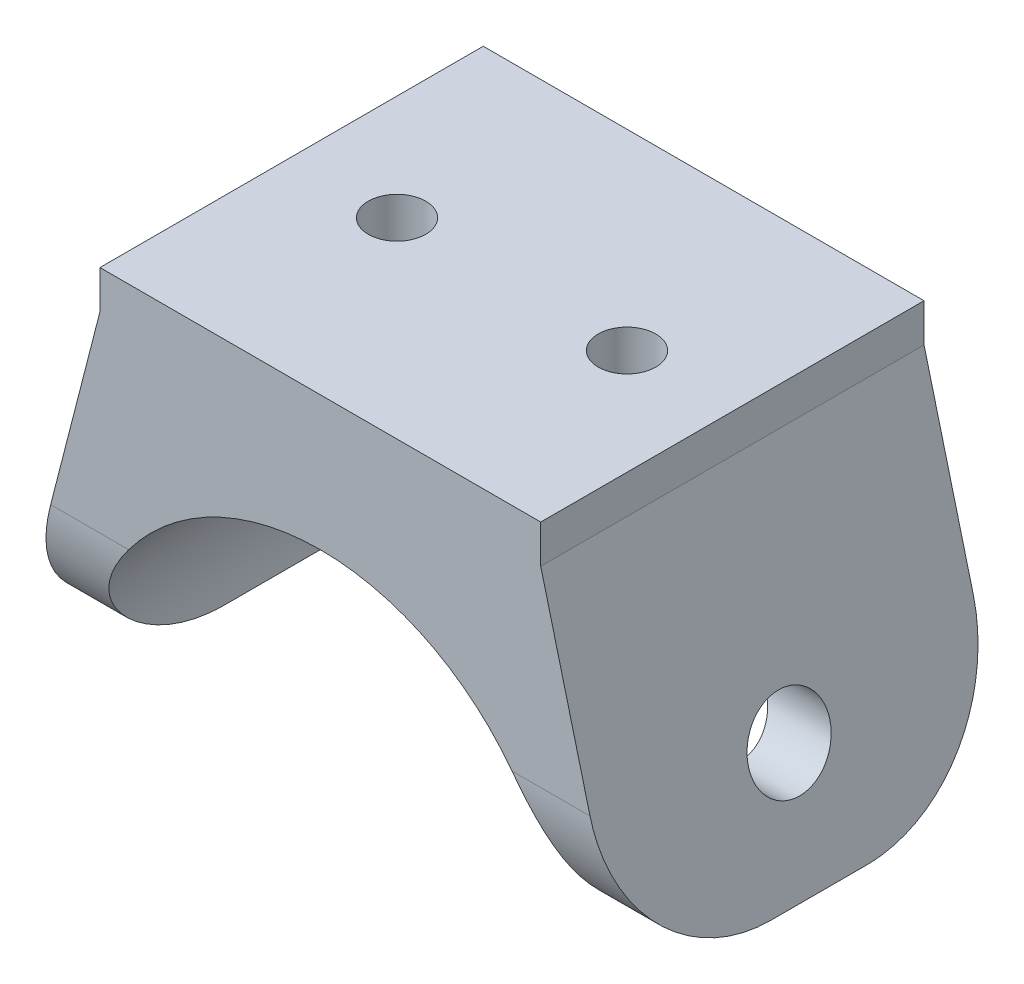
from build123d import *

# Parameters (mm, degrees)
EXTRUDE_1_DEPTH          = 40
SKETCH_2_R               = 3
CUT_EXTRUDE_1_DEPTH      = 14
SKETCH_3_R               = 4.25
CUT_EXTRUDE_2_DEPTH      = 33
CUT_EXTRUDE_2_DEPTH_BACK = 33
FILLET_1_R               = 15


with BuildPart() as part:
    # 草圖1 → 填料-伸長1 (new body)
    with BuildSketch(Plane.XY):
        with BuildLine():
            Line((-23, 35), (-32, 0))
            Line((-32, 0), (-25, 0))
            ThreePointArc((-25, 0), (0, 25), (25, 0))
            Line((25, 0), (32, 0))
            Line((32, 0), (23, 35))
            Line((23, 35), (23, 39))
            Line((23, 39), (-23, 39))
            Line((-23, 39), (-23, 35))
        make_face()
    extrude(amount=EXTRUDE_1_DEPTH)

    # 草圖2 → 除料-伸長1 (cut)
    with BuildSketch(Plane(origin=(0, 39, 0), x_dir=(1, 0, 0), z_dir=(0, 1, 0))):
        with Locations((-12, -20)):
            Circle(SKETCH_2_R)
        with Locations((12, -20)):
            Circle(SKETCH_2_R)
    extrude(amount=-CUT_EXTRUDE_1_DEPTH, mode=Mode.SUBTRACT)

    # 草圖3 → 除料-伸長2 (cut, two sides)
    with BuildSketch(Plane(origin=(0, 0, 0), x_dir=(0, 0, -1), z_dir=(1, 0, 0))) as cut_extrude_2_sk:
        with Locations((-20, 12)):
            Circle(SKETCH_3_R)
    extrude(amount=CUT_EXTRUDE_2_DEPTH, mode=Mode.SUBTRACT)
    extrude(cut_extrude_2_sk.sketch, amount=-CUT_EXTRUDE_2_DEPTH_BACK, mode=Mode.SUBTRACT)

    # 圓角1
    fillet_1_edges = [part.edges().sort_by_distance(p)[0] for p in [
        (-28.5, 0, 0),
        (-28.5, 0, 40),
        (28.5, 0, 40),
        (28.5, 0, 0),
    ]]
    fillet(fillet_1_edges, radius=FILLET_1_R)


solid = part.part
